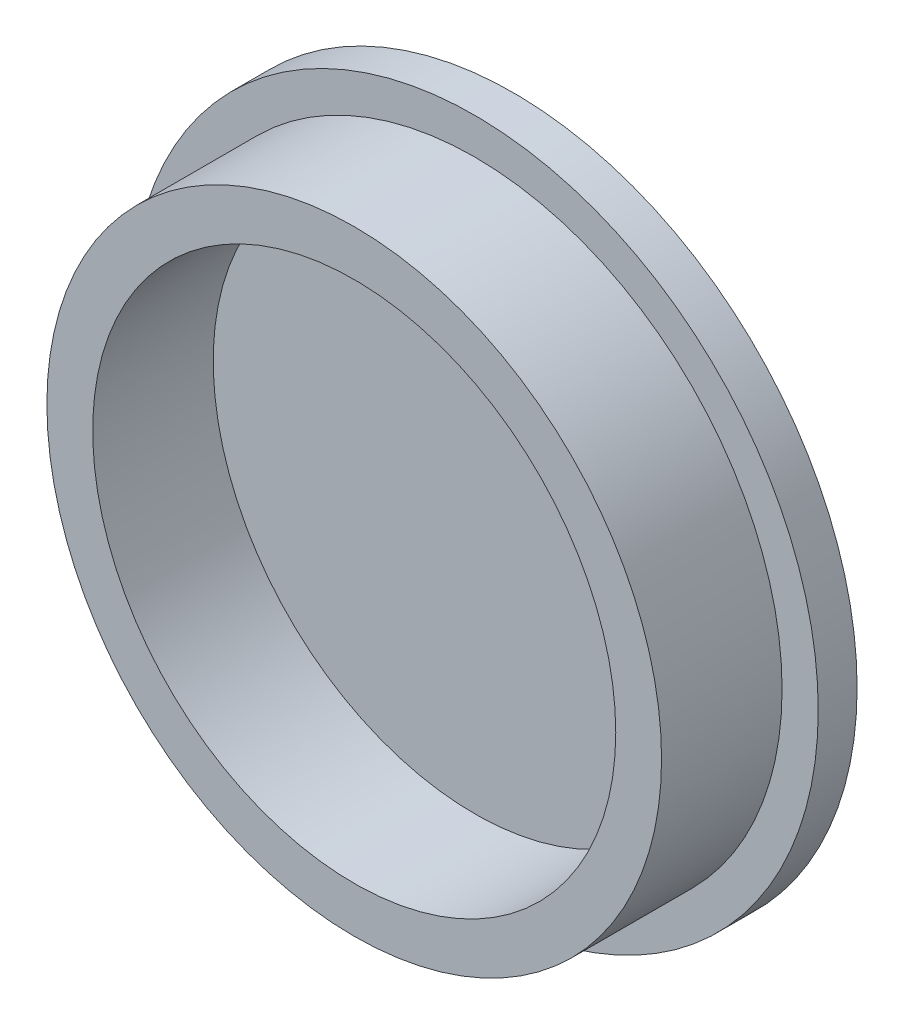
from build123d import *


with BuildPart() as part:
    # Sketch1 → Revolve1 (revolve)
    with BuildSketch(Plane(origin=(0, 0, 0), x_dir=(0, 0, -1), z_dir=(1, 0, 0))):
        Polygon((14.265821229, 0), (14.265821229, 57), (7.815821229, 57), (7.815821229, 51), (-12.184178771, 51), (-12.184178771, 43.4), (7.815821229, 43.4), (7.815821229, 0), align=None)
    revolve(axis=Axis((0, 0, 42.98701676), (0, 0, -1)))


solid = part.part
